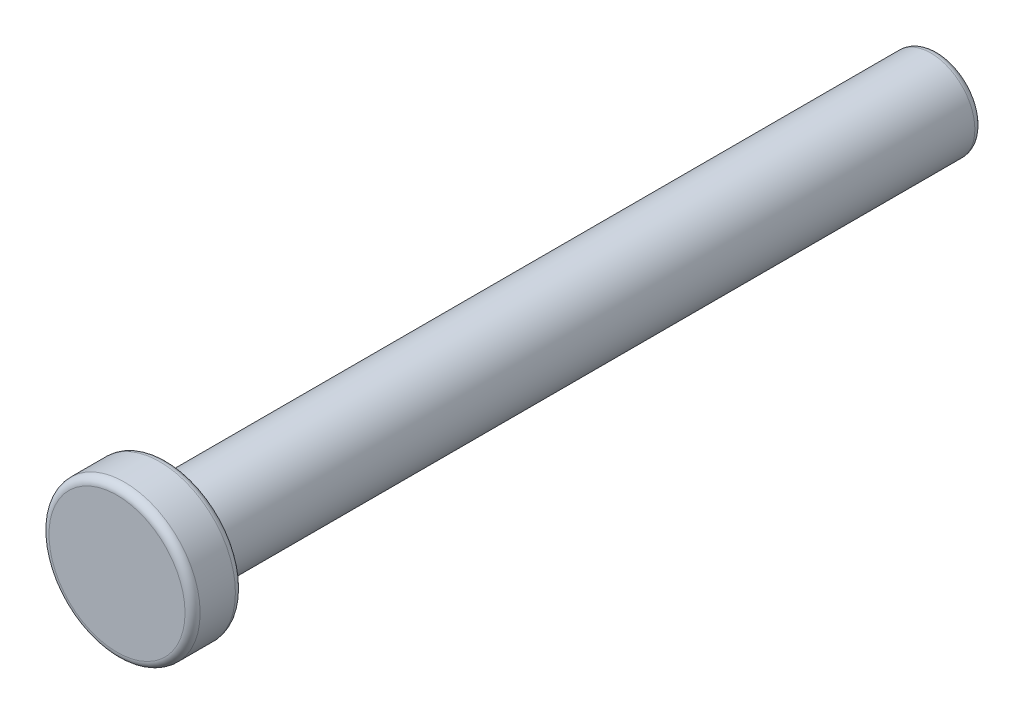
from build123d import *

# Parameters (mm, degrees)
SKETCH_1_R      = 3
EXTRUDE_1_DEPTH = 2
SKETCH_1_3_R    = 1.75
EXTRUDE_2_DEPTH = 30.6
FILLET_1_R      = 0.3


with BuildPart() as part:
    # 草图1 → 凸台-拉伸1 (new body)
    with BuildSketch(Plane.XY):
        Circle(SKETCH_1_R)
    extrude(amount=EXTRUDE_1_DEPTH)

    # 草图1<3> → 凸台-拉伸2 (add)
    with BuildSketch(Plane.XY):
        Circle(SKETCH_1_3_R)
    extrude(amount=-EXTRUDE_2_DEPTH)

    # 圆角1
    fillet_1_edges = [part.edges().sort_by_distance(p)[0] for p in [
        (-3, 0, 0),
        (-1.75, 0, 0),
        (-3, 0, 2),
        (-1.75, 0, -30.6),
    ]]
    fillet(fillet_1_edges, radius=FILLET_1_R)


solid = part.part
